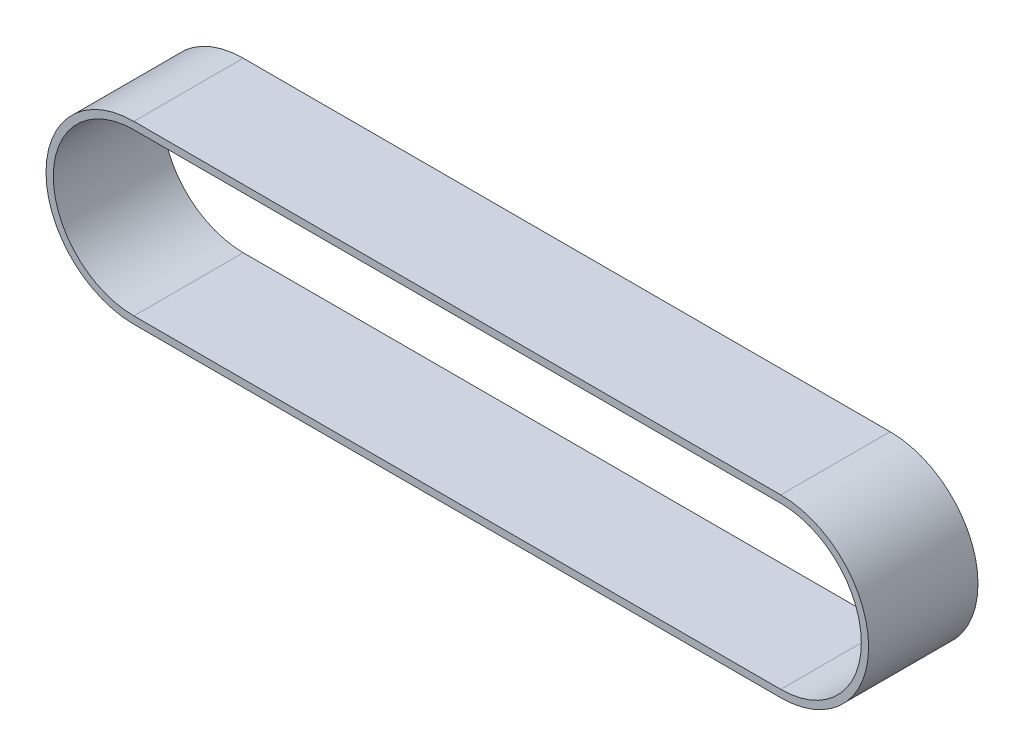
from build123d import *

# Parameters (mm, degrees)
EXTRUDE_1_DEPTH = 15


with BuildPart() as part:
    # 草图1 → 凸台-拉伸1 (new body)
    with BuildSketch(Plane.XY):
        with BuildLine():
            Line((-44.35, 12.05), (44.35, 12.05))
            ThreePointArc((44.35, 12.05), (56.4, 0), (44.35, -12.05))
            Line((44.35, -12.05), (-44.35, -12.05))
            ThreePointArc((-44.35, -12.05), (-56.4, 0), (-44.35, 12.05))
        make_face()
        with BuildLine():
            Line((-44.35, 11.05), (44.35, 11.05))
            ThreePointArc((44.35, 11.05), (55.4, 0), (44.35, -11.05))
            Line((44.35, -11.05), (-44.35, -11.05))
            ThreePointArc((-44.35, -11.05), (-55.4, 0), (-44.35, 11.05))
        make_face(mode=Mode.SUBTRACT)
    extrude(amount=EXTRUDE_1_DEPTH)


solid = part.part
